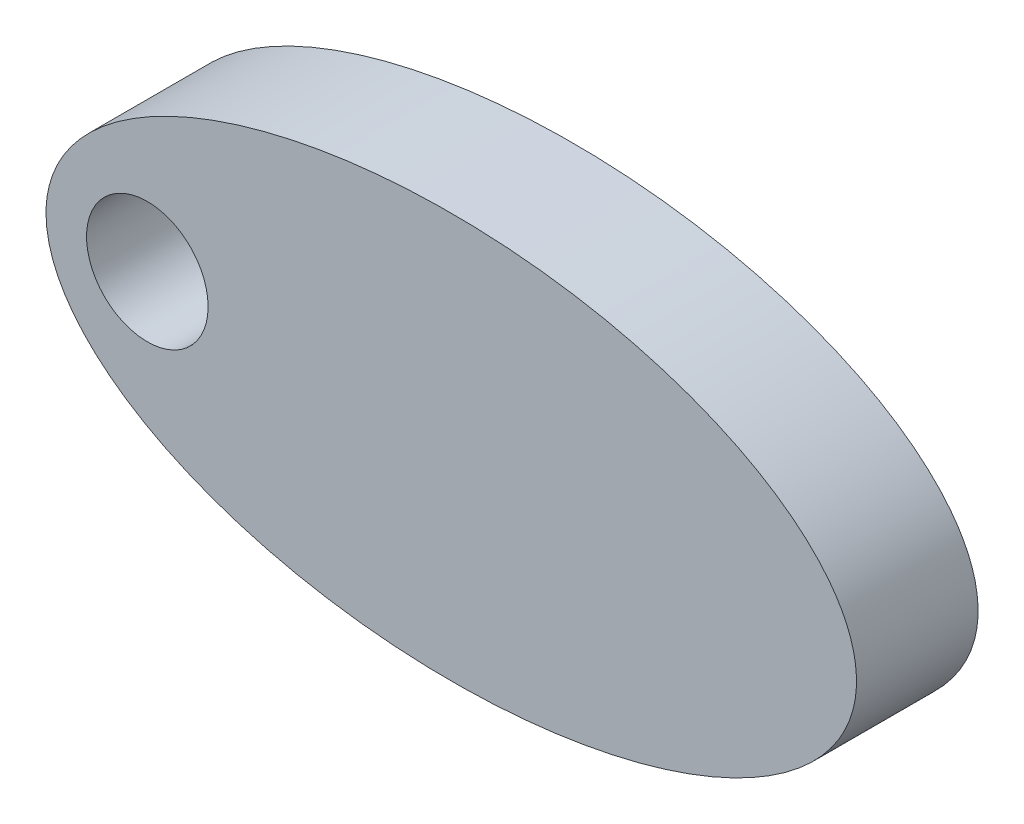
from build123d import *

# Parameters (mm, degrees)
SKETCH1_RX          = 10
SKETCH1_RY          = 5
SKETCH1_R           = 1.5
BOSS_EXTRUDE1_DEPTH = 3


with BuildPart() as part:
    # Sketch1 → Boss-Extrude1 (new body)
    with BuildSketch(Plane.XY):
        with Locations(Location((0, 0), (0, 0, 180))):
            Ellipse(SKETCH1_RX, SKETCH1_RY)
        with Locations((-7.5, 0)):
            Circle(SKETCH1_R, mode=Mode.SUBTRACT)
    extrude(amount=BOSS_EXTRUDE1_DEPTH)


solid = part.part
